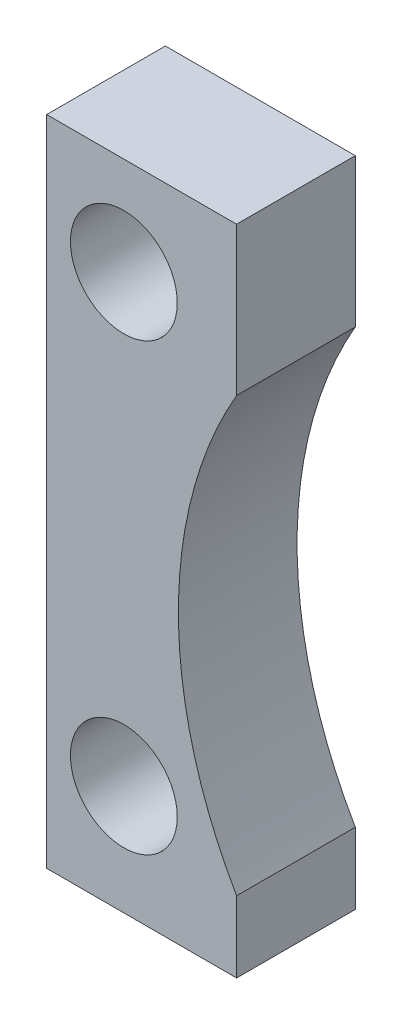
from build123d import *

# Parameters (mm, degrees)
Y_KSEKLIK_EKSTR_ZYON1_DEPTH = 10
IZIM2_R                     = 9
KES_EKSTR_ZYON1_DEPTH       = 21


with BuildPart() as part:
    # Çizim1 → Yükseklik-Ekstrüzyon1 (new body, symmetric)
    with BuildSketch(Plane.XY):
        with BuildLine():
            Line((0, 0), (0, 110))
            Line((0, 110), (32, 110))
            Line((32, 110), (32, 85))
            ThreePointArc((32, 85), (22.190316578, 48.5), (32, 12))
            Line((32, 12), (32, 0))
            Line((32, 0), (0, 0))
        make_face()
    extrude(amount=Y_KSEKLIK_EKSTR_ZYON1_DEPTH, both=True)

    # Çizim2 → Kes-Ekstrüzyon1 (cut, through all)
    with BuildSketch(Plane.XY.offset(10)):
        with Locations((13, 93.5)):
            Circle(IZIM2_R)
        with Locations((13, 18.5)):
            Circle(IZIM2_R)
    extrude(amount=-KES_EKSTR_ZYON1_DEPTH, mode=Mode.SUBTRACT)


solid = part.part
